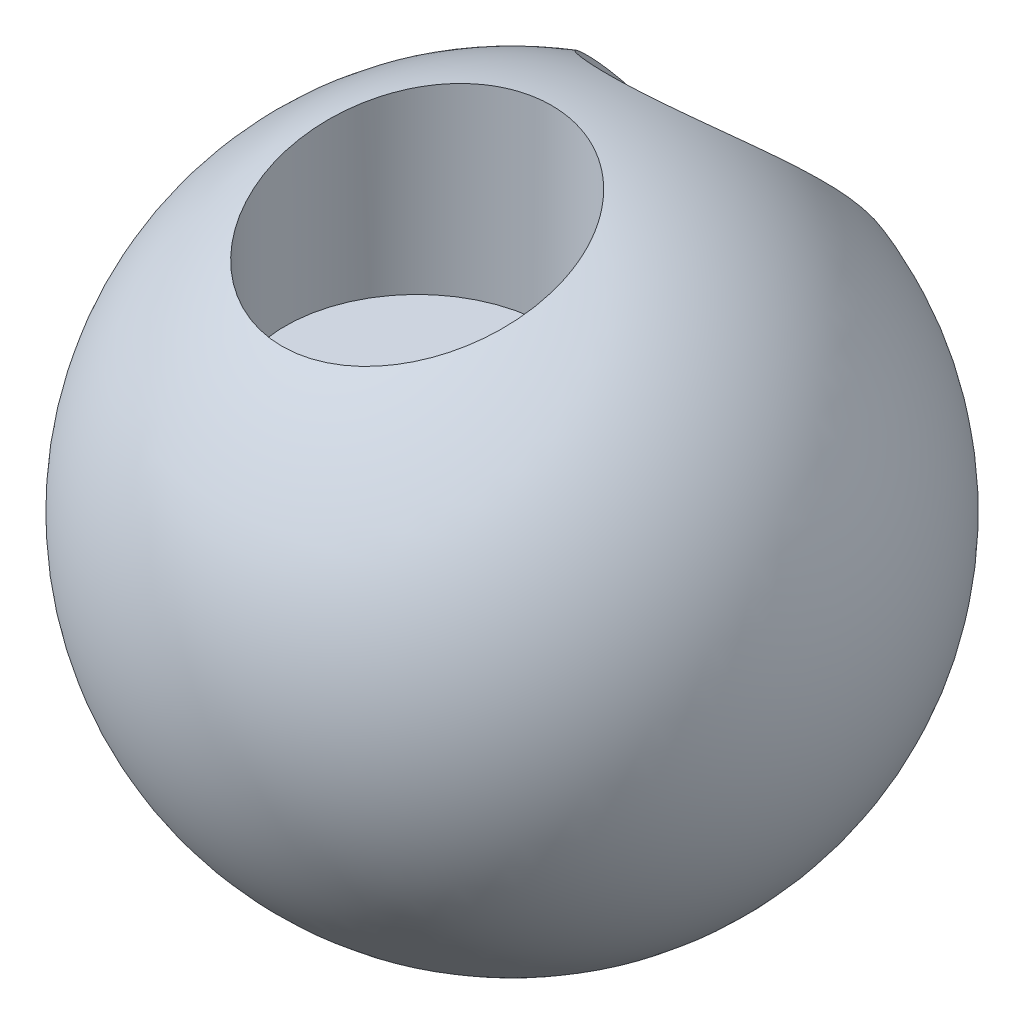
from build123d import *

# Parameters (mm, degrees)
SKETCH6_R          = 40
CUT_EXTRUDE3_DEPTH = 59.294788524860515
SKETCH10_R         = 35.361197
CUT_EXTRUDE6_DEPTH = 199.0000000000001
SKETCH13_R         = 11.999999999999975
CUT_EXTRUDE7_DEPTH = 65


with BuildPart() as part:
    # Sketch2 → Revolve2 (revolve)
    with BuildSketch(Plane.XY):
        with BuildLine():
            Line((0, 100), (2.776e-14, -100))
            ThreePointArc((2.776e-14, -100), (-100, 1.225e-14), (0, 100))
        make_face()
    revolve(axis=Axis((0, 100, 0), (1.4e-16, -1, 0)))

    # Sketch6 → Cut-Extrude3 (cut)
    with BuildSketch(Plane(origin=(-2.5379788603345292, 100, 26.23220958860291), x_dir=(-1, 0, 0), z_dir=(0, -1, 0))):
        with Locations(Location((0, 0, 0), (0, 0, 139.019257533))):
            Circle(SKETCH6_R)
    extrude(amount=CUT_EXTRUDE3_DEPTH, mode=Mode.SUBTRACT)

    # Sketch10 → Cut-Extrude6 (cut)
    with BuildSketch(Plane(origin=(-2.879635505276285, 100, -0.1784267377198251), x_dir=(1, 0, 0), z_dir=(0, 1, 0))):
        with Locations((0, 71.71708866685675)):
            Circle(SKETCH10_R)
    extrude(amount=-CUT_EXTRUDE6_DEPTH, mode=Mode.SUBTRACT)

    # Sketch13 → Cut-Extrude7 (cut, symmetric)
    with BuildSketch(Plane(origin=(0, 0, 0), x_dir=(0, 0, -1), z_dir=(1, 0, 0))):
        with Locations((60, 0)):
            Circle(SKETCH13_R)
    extrude(amount=CUT_EXTRUDE7_DEPTH, both=True, mode=Mode.SUBTRACT)


solid = part.part
